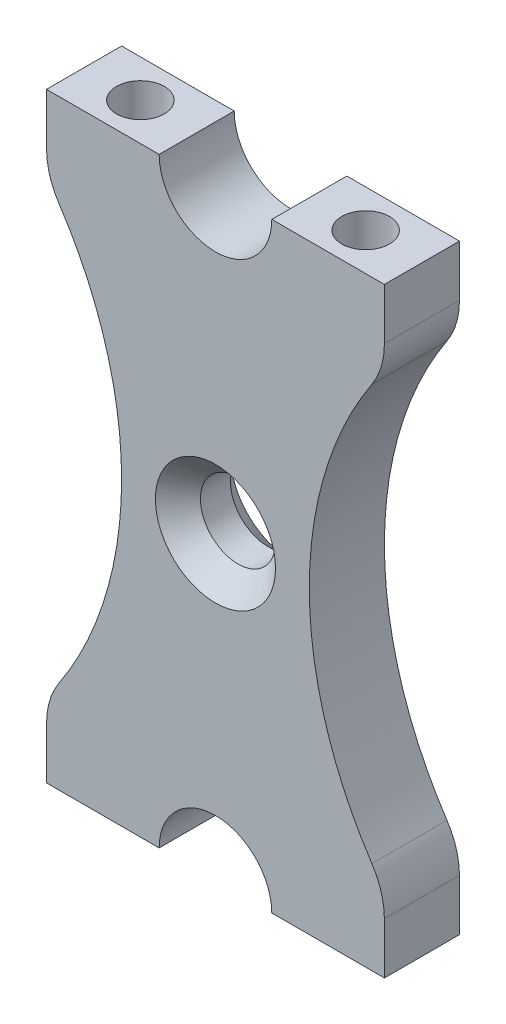
from build123d import *

# Parameters (mm, degrees)
SKETCH1_W                       = 28.575
SKETCH1_H                       = 50.8
BOSS_EXTRUDE1_DEPTH             = 6.35
F_10_32_TAPPED_HOLE1_AT_2_COUNT = 2
F_10_32_TAPPED_HOLE1_AT_2_PITCH = 19.05
F_1_4_0_25_DIAMETER_HOLE1_D     = 6.35
F_1_4_0_25_DIAMETER_HOLE1_DEPTH = 10.668
F_1_4_0_25_DIAMETER_HOLE1_TIP   = 1.907732465
CHAMFER1_SIZE                   = 1.905
CUT_EXTRUDE1_DEPTH              = 7.35
FILLET1_R                       = 6.35


with BuildPart() as part:
    # Sketch1 → Boss-Extrude1 (new body)
    with BuildSketch(Plane.XY):
        Rectangle(SKETCH1_W, SKETCH1_H)
    extrude(amount=BOSS_EXTRUDE1_DEPTH)

    # Sketch3 → #10-32 Tapped Hole1 (revolve, cut)
    with BuildSketch(Plane(origin=(-9.525, 25.4, 3.175), x_dir=(0, 0, 1), z_dir=(1, 0, 0))):
        Polygon((0, 0), (0, 10.865317848), (2.0193, 9.652), (2.0193, 0), align=None)
    f_10_32_tapped_hole1 = revolve(axis=Axis((-9.525, 31.75, 3.175), (0, -1, 0)), mode=Mode.SUBTRACT)

    # #10-32 Tapped Hole1 at 2: #10-32 Tapped Hole1 ×2
    with Locations(*[(i * F_10_32_TAPPED_HOLE1_AT_2_PITCH, 0, 0) for i in range(1, F_10_32_TAPPED_HOLE1_AT_2_COUNT)]):
        add(f_10_32_tapped_hole1, mode=Mode.SUBTRACT)

    # Mirror1: #10-32 Tapped Hole1 across plane
    add(f_10_32_tapped_hole1.mirror(Plane.ZX), mode=Mode.SUBTRACT)

    # Mirror1 copy 1 sketch → Mirror1 copy 1 (revolve, cut)
    with BuildSketch(Plane(origin=(9.525, -25.4, 3.175), x_dir=(0, 0, 1), z_dir=(1, 0, 0))):
        Polygon((0, 0), (0, -10.865317848), (2.0193, -9.652), (2.0193, 0), align=None)
    revolve(axis=Axis((9.525, -31.75, 3.175), (0, -1, 0)), mode=Mode.SUBTRACT)

    # 1/4 (0.25) Diameter Hole1
    with Locations(Plane.XY.offset(6.35)):
        with Locations((0, 0)):
            Hole(F_1_4_0_25_DIAMETER_HOLE1_D / 2, depth=F_1_4_0_25_DIAMETER_HOLE1_DEPTH)
            with Locations((0, 0, -(F_1_4_0_25_DIAMETER_HOLE1_DEPTH + F_1_4_0_25_DIAMETER_HOLE1_TIP / 2))):  # 118° drill point
                Cone(0, F_1_4_0_25_DIAMETER_HOLE1_D / 2, F_1_4_0_25_DIAMETER_HOLE1_TIP, mode=Mode.SUBTRACT)

    # Chamfer1
    chamfer1_edges = [part.edges().sort_by_distance(p)[0] for p in [
        (3.175, 0, 0),
        (3.175, 0, 6.35),
    ]]
    chamfer(chamfer1_edges, length=CHAMFER1_SIZE)

    # Sketch6 → Cut-Extrude1 (cut, through all)
    with BuildSketch(Plane.XY.offset(6.35)):
        with BuildLine():
            Line((-14.2875, 19.05), (-14.2875, -19.05))
            ThreePointArc((-14.2875, -19.05), (-7.9375, 0), (-14.2875, 19.05))
        make_face()
        with BuildLine():
            Line((14.2875, -19.05), (14.2875, 19.05))
            ThreePointArc((14.2875, 19.05), (7.9375, 0), (14.2875, -19.05))
        make_face()
        with BuildLine():
            Line((-4.7625, 25.4), (4.7625, 25.4))
            ThreePointArc((4.7625, 25.4), (0, 20.6375), (-4.7625, 25.4))
        make_face()
        with BuildLine():
            Line((-4.7625, -25.4), (4.7625, -25.4))
            ThreePointArc((4.7625, -25.4), (0, -20.6375), (-4.7625, -25.4))
        make_face()
    extrude(amount=-CUT_EXTRUDE1_DEPTH, mode=Mode.SUBTRACT)

    # Fillet1
    fillet1_edges = [part.edges().sort_by_distance(p)[0] for p in [
        (-14.2875, 19.05, 3.175),
        (-14.2875, -19.05, 3.175),
        (14.2875, -19.05, 3.175),
        (14.2875, 19.05, 3.175),
    ]]
    fillet(fillet1_edges, radius=FILLET1_R)


solid = part.part
